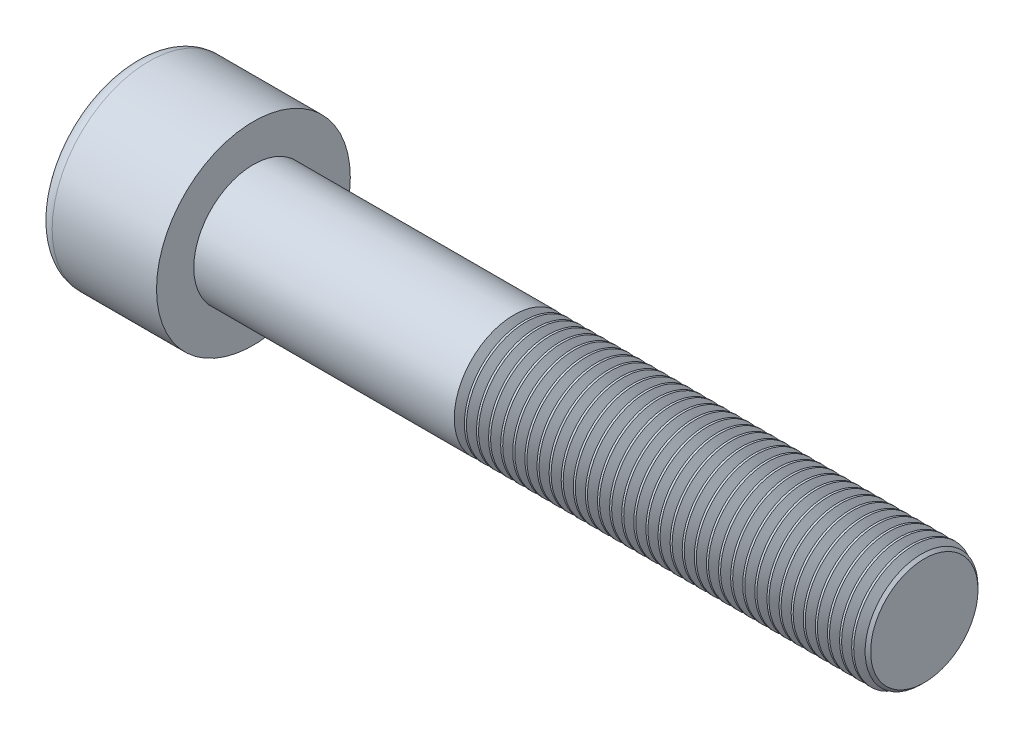
from build123d import *

# Parameters (mm, degrees)
SKETCH1_R           = 6.5
BASEHEAD_DEPTH      = 8
SKETCH2_R           = 4
BASEBODY_DEPTH      = 45
HEXAGONSOCKET_DEPTH = 4
TOPFILLET_R         = 1
CHAMFER1_SIZE       = 0.4
LPATTERN10_COUNT    = 34
LPATTERN10_PITCH    = 0.8118


with BuildPart() as part:
    # Sketch1 → BaseHead (new body)
    with BuildSketch(Plane(origin=(0, 0, 0), x_dir=(0, 0, -1), z_dir=(1, 0, 0))):
        Circle(SKETCH1_R)
    extrude(amount=BASEHEAD_DEPTH)

    # Sketch2 → BaseBody (add)
    with BuildSketch(Plane(origin=(8, 0, 0), x_dir=(0, 0, -1), z_dir=(1, 0, 0))):
        Circle(SKETCH2_R)
    extrude(amount=BASEBODY_DEPTH)

    # Sketch3 → HexagonSocket (cut)
    with BuildSketch(Plane(origin=(0, 0, 0), x_dir=(0, 0, -1), z_dir=(1, 0, 0))):
        Polygon((3.464101615, 0), (1.732050808, 3), (-1.732050808, 3), (-3.464101615, 0), (-1.732050808, -3), (1.732050808, -3), align=None)
    extrude(amount=HEXAGONSOCKET_DEPTH, mode=Mode.SUBTRACT)

    # Sketch4 → Cut-Revolve1 (revolve, cut)
    with BuildSketch(Plane(origin=(-4.19613823, 0.75, 0), x_dir=(-1, 0, 0), z_dir=(0, 0, 1))):
        Polygon((-8.19613823, 3.75), (-9.928189037, 0.75), (-8.19613823, 0.75), align=None)
    revolve(axis=Axis((0.838992387, 0, 0), (-1, 0, 0)), mode=Mode.SUBTRACT)

    # TopFillet
    topfillet_edges = [part.edges().sort_by_distance(p)[0] for p in [
        (0, 0, 6.5),
    ]]
    fillet(topfillet_edges, radius=TOPFILLET_R)

    # Chamfer1
    chamfer1_edges = [part.edges().sort_by_distance(p)[0] for p in [
        (53, 0, 4),
    ]]
    chamfer(chamfer1_edges, length=CHAMFER1_SIZE)

    # Sketch5 → Cut-Revolve10 (revolve, cut)
    with BuildSketch(Plane.XY):
        Polygon((52.6, 3.414133814), (52.93825, 4), (52.93825, 4.6765), (52.26175, 4.6765), (52.26175, 4), align=None)
    cut_revolve10 = revolve(axis=Axis((0, 0, 0), (1, 0, 0)), mode=Mode.SUBTRACT)

    # LPattern10: Cut-Revolve10 ×34
    with Locations(*[(-i * LPATTERN10_PITCH, 0, 0) for i in range(1, LPATTERN10_COUNT)]):
        add(cut_revolve10, mode=Mode.SUBTRACT)


solid = part.part
